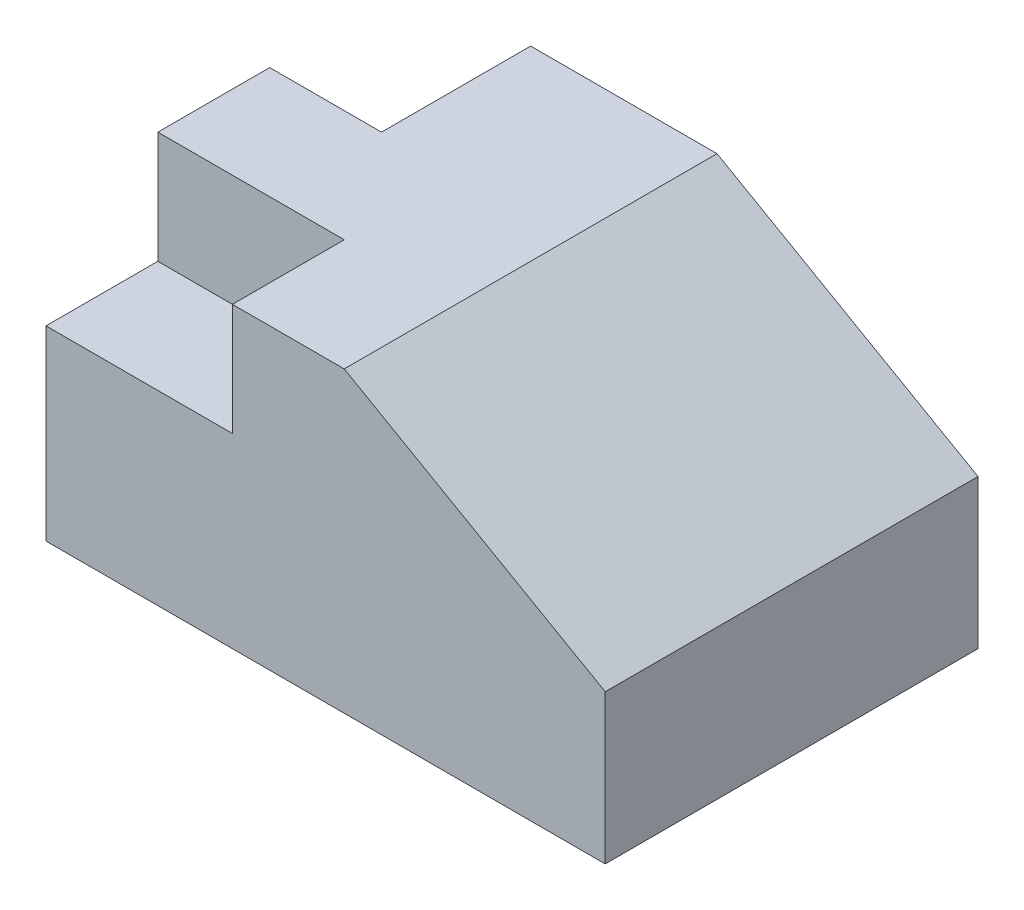
from build123d import *

# Parameters (mm, degrees)
BOSS_EXTRUDE1_DEPTH = 100
SKETCH2_W           = 50
SKETCH2_H           = 30
CUT_EXTRUDE1_DEPTH  = 30
SKETCH3_W           = 30
SKETCH3_H           = 40
CUT_EXTRUDE2_DEPTH  = 80


with BuildPart() as part:
    # Sketch1 → Boss-Extrude1 (new body)
    with BuildSketch(Plane.XY):
        Polygon((-53.543307087, -47.454068241), (96.456692913, -47.454068241), (96.456692913, -7.454068241), (26.456692913, 32.545931759), (-53.543307087, 32.545931759), align=None)
    extrude(amount=-BOSS_EXTRUDE1_DEPTH)

    # Sketch2 → Cut-Extrude1 (cut)
    with BuildSketch(Plane.XY):
        with Locations((-28.543307087, 17.545931759)):
            Rectangle(SKETCH2_W, SKETCH2_H)
    extrude(amount=-CUT_EXTRUDE1_DEPTH, mode=Mode.SUBTRACT)

    # Sketch3 → Cut-Extrude2 (cut)
    with BuildSketch(Plane(origin=(0, 32.545931759, 0), x_dir=(1, 0, 0), z_dir=(0, 1, 0))):
        with Locations((-38.543307087, 80)):
            Rectangle(SKETCH3_W, SKETCH3_H)
    extrude(amount=-CUT_EXTRUDE2_DEPTH, mode=Mode.SUBTRACT)


solid = part.part
